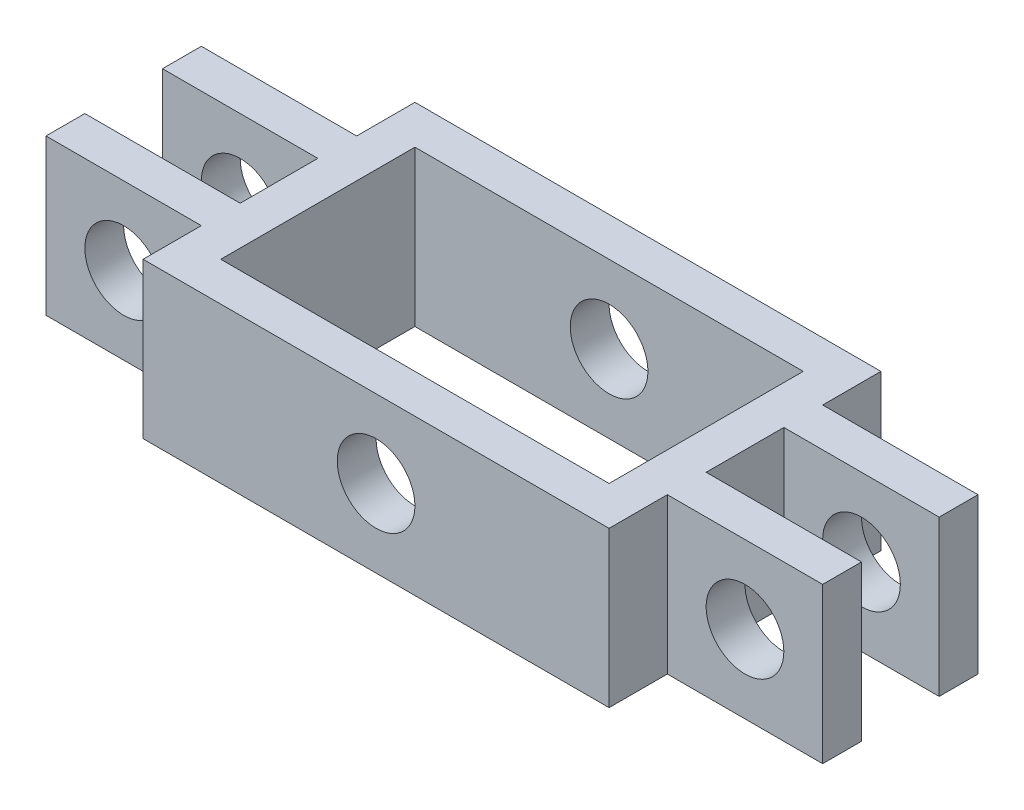
from build123d import *

# Parameters (mm, degrees)
SKETCH2_W           = 60
SKETCH2_H           = 35
SKETCH2_W_2         = 50
SKETCH2_H_2         = 25
BOSS_EXTRUDE1_DEPTH = 20
SKETCH3_R           = 5
CUT_EXTRUDE1_DEPTH  = 36
SKETCH4_W           = 20
SKETCH4_H           = 20
BOSS_EXTRUDE2_DEPTH = 20
SKETCH5_W           = 20
SKETCH5_H           = 20
BOSS_EXTRUDE3_DEPTH = 20
SKETCH6_R           = 5
CUT_EXTRUDE2_DEPTH  = 28.5
SKETCH7_W           = 20
SKETCH7_H           = 10
CUT_EXTRUDE3_DEPTH  = 21


with BuildPart() as part:
    # Sketch2 → Boss-Extrude1 (new body)
    with BuildSketch(Plane(origin=(0, 0, 0), x_dir=(1, 0, 0), z_dir=(0, 1, 0))):
        Rectangle(SKETCH2_W, SKETCH2_H)
        Rectangle(SKETCH2_W_2, SKETCH2_H_2, mode=Mode.SUBTRACT)
    extrude(amount=BOSS_EXTRUDE1_DEPTH)

    # Sketch3 → Cut-Extrude1 (cut, through all)
    with BuildSketch(Plane.XY.offset(17.5)):
        with Locations((0, 10)):
            Circle(SKETCH3_R)
    extrude(amount=-CUT_EXTRUDE1_DEPTH, mode=Mode.SUBTRACT)

    # Sketch4 → Boss-Extrude2 (add)
    with BuildSketch(Plane.ZY.offset(30)):
        with Locations((0, 10)):
            Rectangle(SKETCH4_W, SKETCH4_H)
    extrude(amount=BOSS_EXTRUDE2_DEPTH)

    # Sketch5 → Boss-Extrude3 (add)
    with BuildSketch(Plane(origin=(30, 0, 0), x_dir=(0, 0, -1), z_dir=(1, 0, 0))):
        with Locations((0, 10)):
            Rectangle(SKETCH5_W, SKETCH5_H)
    extrude(amount=BOSS_EXTRUDE3_DEPTH)

    # Sketch6 → Cut-Extrude2 (cut, through all)
    with BuildSketch(Plane.XY.offset(10)):
        with Locations((-40, 10)):
            Circle(SKETCH6_R)
        with Locations((40, 10)):
            Circle(SKETCH6_R)
    extrude(amount=-CUT_EXTRUDE2_DEPTH, mode=Mode.SUBTRACT)

    # Sketch7 → Cut-Extrude3 (cut, through all)
    with BuildSketch(Plane(origin=(0, 20, 0), x_dir=(1, 0, 0), z_dir=(0, 1, 0))):
        with Locations((40, 0)):
            Rectangle(SKETCH7_W, SKETCH7_H)
        with Locations((-40, 0)):
            Rectangle(SKETCH7_W, SKETCH7_H)
    extrude(amount=-CUT_EXTRUDE3_DEPTH, mode=Mode.SUBTRACT)


solid = part.part
